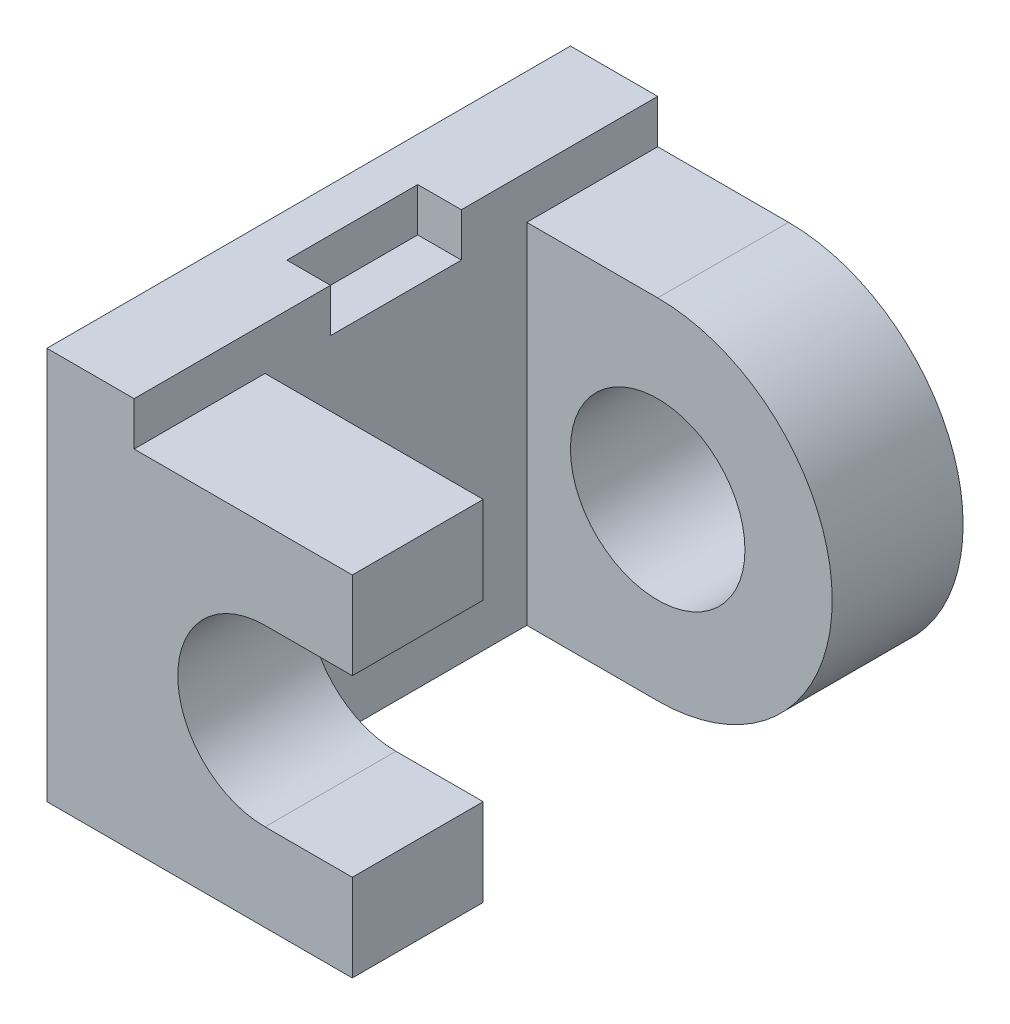
from build123d import *

# Parameters (mm, degrees)
BOSS_EXTRUDE1_DEPTH = 9
SKETCH3_R           = 2
SKETCH3_W           = 7
SKETCH3_H           = 1
CUT_EXTRUDE4_DEPTH  = 8
SKETCH4_W           = 1
SKETCH4_H           = 3
CUT_EXTRUDE5_DEPTH  = 1
SKETCH5_R           = 2
CUT_EXTRUDE6_DEPTH  = 11


with BuildPart() as part:
    # Sketch2 → Boss-Extrude1 (new body)
    with BuildSketch(Plane(origin=(0, 0, 0), x_dir=(1, 0, 0), z_dir=(0, 1, 0))):
        Polygon((0, 0), (0, 12), (9, 12), (9, 9), (2, 9), (2, 3), (7, 3), (7, 0), align=None)
    extrude(amount=BOSS_EXTRUDE1_DEPTH)

    # Sketch3 → Cut-Extrude4 (cut)
    with BuildSketch(Plane.XY):
        Polygon((8.855862573, 6), (7, 6), (7, 4), (7, 2), (8.855862573, 2), align=None)
        with Locations((5, 4)):
            Circle(SKETCH3_R)
        with BuildLine():
            Line((7, 4), (7, 6))
            Line((7, 6), (5, 6))
            ThreePointArc((5, 6), (6.414213562, 5.414213562), (7, 4))
        make_face()
        with BuildLine():
            Line((7, 2), (7, 4))
            ThreePointArc((7, 4), (6.414213562, 2.585786438), (5, 2))
            Line((5, 2), (7, 2))
        make_face()
        with Locations((5.5, 8.5)):
            Rectangle(SKETCH3_W, SKETCH3_H)
    extrude(amount=-CUT_EXTRUDE4_DEPTH, mode=Mode.SUBTRACT)

    # Sketch4 → Cut-Extrude5 (cut)
    with BuildSketch(Plane(origin=(0, 9, 0), x_dir=(1, 0, 0), z_dir=(0, 1, 0))):
        with Locations((1.5, 6)):
            Rectangle(SKETCH4_W, SKETCH4_H)
    extrude(amount=-CUT_EXTRUDE5_DEPTH, mode=Mode.SUBTRACT)

    # Sketch5 → Cut-Extrude6 (cut)
    with BuildSketch(Plane.XY.offset(-9)):
        Polygon((9, 9), (2, 9), (2, 8), (5, 8), (9, 8), align=None)
        with Locations((5, 4)):
            Circle(SKETCH5_R)
        with BuildLine():
            Line((9, 4.000000022), (9, 8))
            Line((9, 8), (5, 8))
            ThreePointArc((5, 8), (7.828427117, 6.828427133), (9, 4.000000022))
        make_face()
        with BuildLine():
            Line((9, 0), (9, 4.000000022))
            ThreePointArc((9, 4.000000022), (7.828427133, 1.171572883), (5, 0))
            Line((5, 0), (9, 0))
        make_face()
    extrude(amount=-CUT_EXTRUDE6_DEPTH, mode=Mode.SUBTRACT)


solid = part.part
